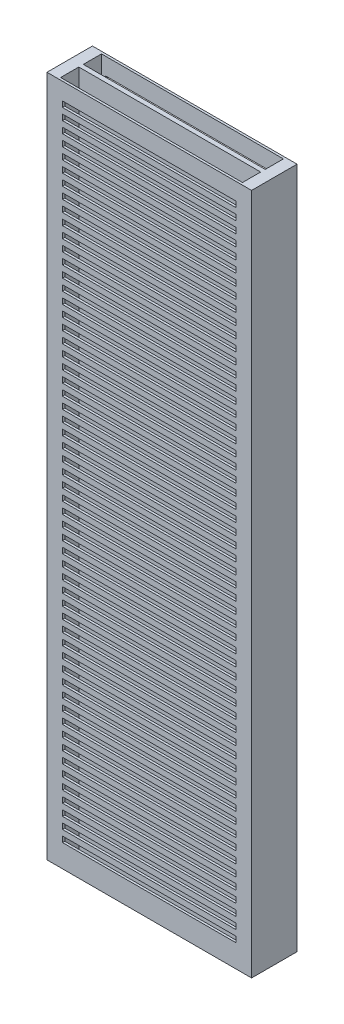
from build123d import *

# Parameters (mm, degrees)
SKETCH1_W                = 9
SKETCH1_H                = 2
BOSS_EXTRUDE1_DEPTH      = 15
CUT_EXTRUDE1_START       = -31
SKETCH2_W                = 8
SKETCH2_H                = 0.8
CUT_EXTRUDE1_DEPTH       = 32
SKETCH3_W                = 7.634272068
SKETCH3_H                = 0.25
CUT_EXTRUDE2_DEPTH       = 0.1
LPATTERN1_COUNT          = 57
LPATTERN1_PITCH          = 0.5
MIRROR2_COPY_1_SKETCH_W  = 7.634272068
MIRROR2_COPY_1_SKETCH_H  = 0.25
MIRROR2_COPY_1_DEPTH     = 0.1
MIRROR2_COPY_2_SKETCH_W  = 7.634272068
MIRROR2_COPY_2_SKETCH_H  = 0.25
MIRROR2_COPY_2_DEPTH     = 0.1
MIRROR2_COPY_3_SKETCH_W  = 7.634272068
MIRROR2_COPY_3_SKETCH_H  = 0.25
MIRROR2_COPY_3_DEPTH     = 0.1
MIRROR2_COPY_4_SKETCH_W  = 7.634272068
MIRROR2_COPY_4_SKETCH_H  = 0.25
MIRROR2_COPY_4_DEPTH     = 0.1
MIRROR2_COPY_5_SKETCH_W  = 7.634272068
MIRROR2_COPY_5_SKETCH_H  = 0.25
MIRROR2_COPY_5_DEPTH     = 0.1
MIRROR2_COPY_6_SKETCH_W  = 7.634272068
MIRROR2_COPY_6_SKETCH_H  = 0.25
MIRROR2_COPY_6_DEPTH     = 0.1
MIRROR2_COPY_7_SKETCH_W  = 7.634272068
MIRROR2_COPY_7_SKETCH_H  = 0.25
MIRROR2_COPY_7_DEPTH     = 0.1
MIRROR2_COPY_8_SKETCH_W  = 7.634272068
MIRROR2_COPY_8_SKETCH_H  = 0.25
MIRROR2_COPY_8_DEPTH     = 0.1
MIRROR2_COPY_9_SKETCH_W  = 7.634272068
MIRROR2_COPY_9_SKETCH_H  = 0.25
MIRROR2_COPY_9_DEPTH     = 0.1
MIRROR2_COPY_10_SKETCH_W = 7.634272068
MIRROR2_COPY_10_SKETCH_H = 0.25
MIRROR2_COPY_10_DEPTH    = 0.1
MIRROR2_COPY_11_SKETCH_W = 7.634272068
MIRROR2_COPY_11_SKETCH_H = 0.25
MIRROR2_COPY_11_DEPTH    = 0.1
MIRROR2_COPY_12_SKETCH_W = 7.634272068
MIRROR2_COPY_12_SKETCH_H = 0.25
MIRROR2_COPY_12_DEPTH    = 0.1
MIRROR2_COPY_13_SKETCH_W = 7.634272068
MIRROR2_COPY_13_SKETCH_H = 0.25
MIRROR2_COPY_13_DEPTH    = 0.1
MIRROR2_COPY_14_SKETCH_W = 7.634272068
MIRROR2_COPY_14_SKETCH_H = 0.25
MIRROR2_COPY_14_DEPTH    = 0.1
MIRROR2_COPY_15_SKETCH_W = 7.634272068
MIRROR2_COPY_15_SKETCH_H = 0.25
MIRROR2_COPY_15_DEPTH    = 0.1
MIRROR2_COPY_16_SKETCH_W = 7.634272068
MIRROR2_COPY_16_SKETCH_H = 0.25
MIRROR2_COPY_16_DEPTH    = 0.1
MIRROR2_COPY_17_SKETCH_W = 7.634272068
MIRROR2_COPY_17_SKETCH_H = 0.25
MIRROR2_COPY_17_DEPTH    = 0.1
MIRROR2_COPY_18_SKETCH_W = 7.634272068
MIRROR2_COPY_18_SKETCH_H = 0.25
MIRROR2_COPY_18_DEPTH    = 0.1
MIRROR2_COPY_19_SKETCH_W = 7.634272068
MIRROR2_COPY_19_SKETCH_H = 0.25
MIRROR2_COPY_19_DEPTH    = 0.1
MIRROR2_COPY_20_SKETCH_W = 7.634272068
MIRROR2_COPY_20_SKETCH_H = 0.25
MIRROR2_COPY_20_DEPTH    = 0.1
MIRROR2_COPY_21_SKETCH_W = 7.634272068
MIRROR2_COPY_21_SKETCH_H = 0.25
MIRROR2_COPY_21_DEPTH    = 0.1
MIRROR2_COPY_22_SKETCH_W = 7.634272068
MIRROR2_COPY_22_SKETCH_H = 0.25
MIRROR2_COPY_22_DEPTH    = 0.1
MIRROR2_COPY_23_SKETCH_W = 7.634272068
MIRROR2_COPY_23_SKETCH_H = 0.25
MIRROR2_COPY_23_DEPTH    = 0.1
MIRROR2_COPY_24_SKETCH_W = 7.634272068
MIRROR2_COPY_24_SKETCH_H = 0.25
MIRROR2_COPY_24_DEPTH    = 0.1
MIRROR2_COPY_25_SKETCH_W = 7.634272068
MIRROR2_COPY_25_SKETCH_H = 0.25
MIRROR2_COPY_25_DEPTH    = 0.1
MIRROR2_COPY_26_SKETCH_W = 7.634272068
MIRROR2_COPY_26_SKETCH_H = 0.25
MIRROR2_COPY_26_DEPTH    = 0.1
MIRROR2_COPY_27_SKETCH_W = 7.634272068
MIRROR2_COPY_27_SKETCH_H = 0.25
MIRROR2_COPY_27_DEPTH    = 0.1
MIRROR2_COPY_28_SKETCH_W = 7.634272068
MIRROR2_COPY_28_SKETCH_H = 0.25
MIRROR2_COPY_28_DEPTH    = 0.1
MIRROR2_COPY_29_SKETCH_W = 7.634272068
MIRROR2_COPY_29_SKETCH_H = 0.25
MIRROR2_COPY_29_DEPTH    = 0.1
MIRROR2_COPY_30_SKETCH_W = 7.634272068
MIRROR2_COPY_30_SKETCH_H = 0.25
MIRROR2_COPY_30_DEPTH    = 0.1
MIRROR2_COPY_31_SKETCH_W = 7.634272068
MIRROR2_COPY_31_SKETCH_H = 0.25
MIRROR2_COPY_31_DEPTH    = 0.1
MIRROR2_COPY_32_SKETCH_W = 7.634272068
MIRROR2_COPY_32_SKETCH_H = 0.25
MIRROR2_COPY_32_DEPTH    = 0.1
MIRROR2_COPY_33_SKETCH_W = 7.634272068
MIRROR2_COPY_33_SKETCH_H = 0.25
MIRROR2_COPY_33_DEPTH    = 0.1
MIRROR2_COPY_34_SKETCH_W = 7.634272068
MIRROR2_COPY_34_SKETCH_H = 0.25
MIRROR2_COPY_34_DEPTH    = 0.1
MIRROR2_COPY_35_SKETCH_W = 7.634272068
MIRROR2_COPY_35_SKETCH_H = 0.25
MIRROR2_COPY_35_DEPTH    = 0.1
MIRROR2_COPY_36_SKETCH_W = 7.634272068
MIRROR2_COPY_36_SKETCH_H = 0.25
MIRROR2_COPY_36_DEPTH    = 0.1
MIRROR2_COPY_37_SKETCH_W = 7.634272068
MIRROR2_COPY_37_SKETCH_H = 0.25
MIRROR2_COPY_37_DEPTH    = 0.1
MIRROR2_COPY_38_SKETCH_W = 7.634272068
MIRROR2_COPY_38_SKETCH_H = 0.25
MIRROR2_COPY_38_DEPTH    = 0.1
MIRROR2_COPY_39_SKETCH_W = 7.634272068
MIRROR2_COPY_39_SKETCH_H = 0.25
MIRROR2_COPY_39_DEPTH    = 0.1
MIRROR2_COPY_40_SKETCH_W = 7.634272068
MIRROR2_COPY_40_SKETCH_H = 0.25
MIRROR2_COPY_40_DEPTH    = 0.1
MIRROR2_COPY_41_SKETCH_W = 7.634272068
MIRROR2_COPY_41_SKETCH_H = 0.25
MIRROR2_COPY_41_DEPTH    = 0.1
MIRROR2_COPY_42_SKETCH_W = 7.634272068
MIRROR2_COPY_42_SKETCH_H = 0.25
MIRROR2_COPY_42_DEPTH    = 0.1
MIRROR2_COPY_43_SKETCH_W = 7.634272068
MIRROR2_COPY_43_SKETCH_H = 0.25
MIRROR2_COPY_43_DEPTH    = 0.1
MIRROR2_COPY_44_SKETCH_W = 7.634272068
MIRROR2_COPY_44_SKETCH_H = 0.25
MIRROR2_COPY_44_DEPTH    = 0.1
MIRROR2_COPY_45_SKETCH_W = 7.634272068
MIRROR2_COPY_45_SKETCH_H = 0.25
MIRROR2_COPY_45_DEPTH    = 0.1
MIRROR2_COPY_46_SKETCH_W = 7.634272068
MIRROR2_COPY_46_SKETCH_H = 0.25
MIRROR2_COPY_46_DEPTH    = 0.1
MIRROR2_COPY_47_SKETCH_W = 7.634272068
MIRROR2_COPY_47_SKETCH_H = 0.25
MIRROR2_COPY_47_DEPTH    = 0.1
MIRROR2_COPY_48_SKETCH_W = 7.634272068
MIRROR2_COPY_48_SKETCH_H = 0.25
MIRROR2_COPY_48_DEPTH    = 0.1
MIRROR2_COPY_49_SKETCH_W = 7.634272068
MIRROR2_COPY_49_SKETCH_H = 0.25
MIRROR2_COPY_49_DEPTH    = 0.1
MIRROR2_COPY_50_SKETCH_W = 7.634272068
MIRROR2_COPY_50_SKETCH_H = 0.25
MIRROR2_COPY_50_DEPTH    = 0.1
MIRROR2_COPY_51_SKETCH_W = 7.634272068
MIRROR2_COPY_51_SKETCH_H = 0.25
MIRROR2_COPY_51_DEPTH    = 0.1
MIRROR2_COPY_52_SKETCH_W = 7.634272068
MIRROR2_COPY_52_SKETCH_H = 0.25
MIRROR2_COPY_52_DEPTH    = 0.1
MIRROR2_COPY_53_SKETCH_W = 7.634272068
MIRROR2_COPY_53_SKETCH_H = 0.25
MIRROR2_COPY_53_DEPTH    = 0.1
MIRROR2_COPY_54_SKETCH_W = 7.634272068
MIRROR2_COPY_54_SKETCH_H = 0.25
MIRROR2_COPY_54_DEPTH    = 0.1
MIRROR2_COPY_55_SKETCH_W = 7.634272068
MIRROR2_COPY_55_SKETCH_H = 0.25
MIRROR2_COPY_55_DEPTH    = 0.1
MIRROR2_COPY_56_SKETCH_W = 7.634272068
MIRROR2_COPY_56_SKETCH_H = 0.25
MIRROR2_COPY_56_DEPTH    = 0.1


with BuildPart() as part:
    # Sketch1 → Boss-Extrude1 (new body, symmetric)
    with BuildSketch(Plane(origin=(0, 0, 0), x_dir=(1, 0, 0), z_dir=(0, 1, 0))):
        Rectangle(SKETCH1_W, SKETCH1_H)
    extrude(amount=BOSS_EXTRUDE1_DEPTH, both=True)

    # Sketch2 → Cut-Extrude1 (cut)
    with BuildSketch(Plane(origin=(0, 15, 0), x_dir=(1, 0, 0), z_dir=(0, 1, 0)).offset(CUT_EXTRUDE1_START)):
        with Locations((0, 0.5)):
            Rectangle(SKETCH2_W, SKETCH2_H)
    cut_extrude1 = extrude(amount=CUT_EXTRUDE1_DEPTH, mode=Mode.SUBTRACT)

    # Mirror1: Cut-Extrude1 across plane
    add(cut_extrude1.mirror(Plane.XY), mode=Mode.SUBTRACT)

    # Sketch3 → Cut-Extrude2 (cut)
    with BuildSketch(Plane.XY.offset(1)):
        with Locations((0, 14.125)):
            Rectangle(SKETCH3_W, SKETCH3_H)
    cut_extrude2 = extrude(amount=-CUT_EXTRUDE2_DEPTH, mode=Mode.SUBTRACT)

    # LPattern1: Cut-Extrude2 ×57
    with Locations(*[(0, -i * LPATTERN1_PITCH, 0) for i in range(1, LPATTERN1_COUNT)]):
        add(cut_extrude2, mode=Mode.SUBTRACT)

    # Mirror2: Cut-Extrude2 across plane
    add(cut_extrude2.mirror(Plane.XY), mode=Mode.SUBTRACT)

    # Mirror2 copy 1 sketch → Mirror2 copy 1 (cut)
    with BuildSketch(Plane(origin=(0, -0.5, -1), x_dir=(1, 0, 0), z_dir=(0, 0, -1))):
        with Locations((0, -14.125)):
            Rectangle(MIRROR2_COPY_1_SKETCH_W, MIRROR2_COPY_1_SKETCH_H)
    extrude(amount=-MIRROR2_COPY_1_DEPTH, mode=Mode.SUBTRACT)

    # Mirror2 copy 2 sketch → Mirror2 copy 2 (cut)
    with BuildSketch(Plane(origin=(0, -1, -1), x_dir=(1, 0, 0), z_dir=(0, 0, -1))):
        with Locations((0, -14.125)):
            Rectangle(MIRROR2_COPY_2_SKETCH_W, MIRROR2_COPY_2_SKETCH_H)
    extrude(amount=-MIRROR2_COPY_2_DEPTH, mode=Mode.SUBTRACT)

    # Mirror2 copy 3 sketch → Mirror2 copy 3 (cut)
    with BuildSketch(Plane(origin=(0, -1.5, -1), x_dir=(1, 0, 0), z_dir=(0, 0, -1))):
        with Locations((0, -14.125)):
            Rectangle(MIRROR2_COPY_3_SKETCH_W, MIRROR2_COPY_3_SKETCH_H)
    extrude(amount=-MIRROR2_COPY_3_DEPTH, mode=Mode.SUBTRACT)

    # Mirror2 copy 4 sketch → Mirror2 copy 4 (cut)
    with BuildSketch(Plane(origin=(0, -2, -1), x_dir=(1, 0, 0), z_dir=(0, 0, -1))):
        with Locations((0, -14.125)):
            Rectangle(MIRROR2_COPY_4_SKETCH_W, MIRROR2_COPY_4_SKETCH_H)
    extrude(amount=-MIRROR2_COPY_4_DEPTH, mode=Mode.SUBTRACT)

    # Mirror2 copy 5 sketch → Mirror2 copy 5 (cut)
    with BuildSketch(Plane(origin=(0, -2.5, -1), x_dir=(1, 0, 0), z_dir=(0, 0, -1))):
        with Locations((0, -14.125)):
            Rectangle(MIRROR2_COPY_5_SKETCH_W, MIRROR2_COPY_5_SKETCH_H)
    extrude(amount=-MIRROR2_COPY_5_DEPTH, mode=Mode.SUBTRACT)

    # Mirror2 copy 6 sketch → Mirror2 copy 6 (cut)
    with BuildSketch(Plane(origin=(0, -3, -1), x_dir=(1, 0, 0), z_dir=(0, 0, -1))):
        with Locations((0, -14.125)):
            Rectangle(MIRROR2_COPY_6_SKETCH_W, MIRROR2_COPY_6_SKETCH_H)
    extrude(amount=-MIRROR2_COPY_6_DEPTH, mode=Mode.SUBTRACT)

    # Mirror2 copy 7 sketch → Mirror2 copy 7 (cut)
    with BuildSketch(Plane(origin=(0, -3.5, -1), x_dir=(1, 0, 0), z_dir=(0, 0, -1))):
        with Locations((0, -14.125)):
            Rectangle(MIRROR2_COPY_7_SKETCH_W, MIRROR2_COPY_7_SKETCH_H)
    extrude(amount=-MIRROR2_COPY_7_DEPTH, mode=Mode.SUBTRACT)

    # Mirror2 copy 8 sketch → Mirror2 copy 8 (cut)
    with BuildSketch(Plane(origin=(0, -4, -1), x_dir=(1, 0, 0), z_dir=(0, 0, -1))):
        with Locations((0, -14.125)):
            Rectangle(MIRROR2_COPY_8_SKETCH_W, MIRROR2_COPY_8_SKETCH_H)
    extrude(amount=-MIRROR2_COPY_8_DEPTH, mode=Mode.SUBTRACT)

    # Mirror2 copy 9 sketch → Mirror2 copy 9 (cut)
    with BuildSketch(Plane(origin=(0, -4.5, -1), x_dir=(1, 0, 0), z_dir=(0, 0, -1))):
        with Locations((0, -14.125)):
            Rectangle(MIRROR2_COPY_9_SKETCH_W, MIRROR2_COPY_9_SKETCH_H)
    extrude(amount=-MIRROR2_COPY_9_DEPTH, mode=Mode.SUBTRACT)

    # Mirror2 copy 10 sketch → Mirror2 copy 10 (cut)
    with BuildSketch(Plane(origin=(0, -5, -1), x_dir=(1, 0, 0), z_dir=(0, 0, -1))):
        with Locations((0, -14.125)):
            Rectangle(MIRROR2_COPY_10_SKETCH_W, MIRROR2_COPY_10_SKETCH_H)
    extrude(amount=-MIRROR2_COPY_10_DEPTH, mode=Mode.SUBTRACT)

    # Mirror2 copy 11 sketch → Mirror2 copy 11 (cut)
    with BuildSketch(Plane(origin=(0, -5.5, -1), x_dir=(1, 0, 0), z_dir=(0, 0, -1))):
        with Locations((0, -14.125)):
            Rectangle(MIRROR2_COPY_11_SKETCH_W, MIRROR2_COPY_11_SKETCH_H)
    extrude(amount=-MIRROR2_COPY_11_DEPTH, mode=Mode.SUBTRACT)

    # Mirror2 copy 12 sketch → Mirror2 copy 12 (cut)
    with BuildSketch(Plane(origin=(0, -6, -1), x_dir=(1, 0, 0), z_dir=(0, 0, -1))):
        with Locations((0, -14.125)):
            Rectangle(MIRROR2_COPY_12_SKETCH_W, MIRROR2_COPY_12_SKETCH_H)
    extrude(amount=-MIRROR2_COPY_12_DEPTH, mode=Mode.SUBTRACT)

    # Mirror2 copy 13 sketch → Mirror2 copy 13 (cut)
    with BuildSketch(Plane(origin=(0, -6.5, -1), x_dir=(1, 0, 0), z_dir=(0, 0, -1))):
        with Locations((0, -14.125)):
            Rectangle(MIRROR2_COPY_13_SKETCH_W, MIRROR2_COPY_13_SKETCH_H)
    extrude(amount=-MIRROR2_COPY_13_DEPTH, mode=Mode.SUBTRACT)

    # Mirror2 copy 14 sketch → Mirror2 copy 14 (cut)
    with BuildSketch(Plane(origin=(0, -7, -1), x_dir=(1, 0, 0), z_dir=(0, 0, -1))):
        with Locations((0, -14.125)):
            Rectangle(MIRROR2_COPY_14_SKETCH_W, MIRROR2_COPY_14_SKETCH_H)
    extrude(amount=-MIRROR2_COPY_14_DEPTH, mode=Mode.SUBTRACT)

    # Mirror2 copy 15 sketch → Mirror2 copy 15 (cut)
    with BuildSketch(Plane(origin=(0, -7.5, -1), x_dir=(1, 0, 0), z_dir=(0, 0, -1))):
        with Locations((0, -14.125)):
            Rectangle(MIRROR2_COPY_15_SKETCH_W, MIRROR2_COPY_15_SKETCH_H)
    extrude(amount=-MIRROR2_COPY_15_DEPTH, mode=Mode.SUBTRACT)

    # Mirror2 copy 16 sketch → Mirror2 copy 16 (cut)
    with BuildSketch(Plane(origin=(0, -8, -1), x_dir=(1, 0, 0), z_dir=(0, 0, -1))):
        with Locations((0, -14.125)):
            Rectangle(MIRROR2_COPY_16_SKETCH_W, MIRROR2_COPY_16_SKETCH_H)
    extrude(amount=-MIRROR2_COPY_16_DEPTH, mode=Mode.SUBTRACT)

    # Mirror2 copy 17 sketch → Mirror2 copy 17 (cut)
    with BuildSketch(Plane(origin=(0, -8.5, -1), x_dir=(1, 0, 0), z_dir=(0, 0, -1))):
        with Locations((0, -14.125)):
            Rectangle(MIRROR2_COPY_17_SKETCH_W, MIRROR2_COPY_17_SKETCH_H)
    extrude(amount=-MIRROR2_COPY_17_DEPTH, mode=Mode.SUBTRACT)

    # Mirror2 copy 18 sketch → Mirror2 copy 18 (cut)
    with BuildSketch(Plane(origin=(0, -9, -1), x_dir=(1, 0, 0), z_dir=(0, 0, -1))):
        with Locations((0, -14.125)):
            Rectangle(MIRROR2_COPY_18_SKETCH_W, MIRROR2_COPY_18_SKETCH_H)
    extrude(amount=-MIRROR2_COPY_18_DEPTH, mode=Mode.SUBTRACT)

    # Mirror2 copy 19 sketch → Mirror2 copy 19 (cut)
    with BuildSketch(Plane(origin=(0, -9.5, -1), x_dir=(1, 0, 0), z_dir=(0, 0, -1))):
        with Locations((0, -14.125)):
            Rectangle(MIRROR2_COPY_19_SKETCH_W, MIRROR2_COPY_19_SKETCH_H)
    extrude(amount=-MIRROR2_COPY_19_DEPTH, mode=Mode.SUBTRACT)

    # Mirror2 copy 20 sketch → Mirror2 copy 20 (cut)
    with BuildSketch(Plane(origin=(0, -10, -1), x_dir=(1, 0, 0), z_dir=(0, 0, -1))):
        with Locations((0, -14.125)):
            Rectangle(MIRROR2_COPY_20_SKETCH_W, MIRROR2_COPY_20_SKETCH_H)
    extrude(amount=-MIRROR2_COPY_20_DEPTH, mode=Mode.SUBTRACT)

    # Mirror2 copy 21 sketch → Mirror2 copy 21 (cut)
    with BuildSketch(Plane(origin=(0, -10.5, -1), x_dir=(1, 0, 0), z_dir=(0, 0, -1))):
        with Locations((0, -14.125)):
            Rectangle(MIRROR2_COPY_21_SKETCH_W, MIRROR2_COPY_21_SKETCH_H)
    extrude(amount=-MIRROR2_COPY_21_DEPTH, mode=Mode.SUBTRACT)

    # Mirror2 copy 22 sketch → Mirror2 copy 22 (cut)
    with BuildSketch(Plane(origin=(0, -11, -1), x_dir=(1, 0, 0), z_dir=(0, 0, -1))):
        with Locations((0, -14.125)):
            Rectangle(MIRROR2_COPY_22_SKETCH_W, MIRROR2_COPY_22_SKETCH_H)
    extrude(amount=-MIRROR2_COPY_22_DEPTH, mode=Mode.SUBTRACT)

    # Mirror2 copy 23 sketch → Mirror2 copy 23 (cut)
    with BuildSketch(Plane(origin=(0, -11.5, -1), x_dir=(1, 0, 0), z_dir=(0, 0, -1))):
        with Locations((0, -14.125)):
            Rectangle(MIRROR2_COPY_23_SKETCH_W, MIRROR2_COPY_23_SKETCH_H)
    extrude(amount=-MIRROR2_COPY_23_DEPTH, mode=Mode.SUBTRACT)

    # Mirror2 copy 24 sketch → Mirror2 copy 24 (cut)
    with BuildSketch(Plane(origin=(0, -12, -1), x_dir=(1, 0, 0), z_dir=(0, 0, -1))):
        with Locations((0, -14.125)):
            Rectangle(MIRROR2_COPY_24_SKETCH_W, MIRROR2_COPY_24_SKETCH_H)
    extrude(amount=-MIRROR2_COPY_24_DEPTH, mode=Mode.SUBTRACT)

    # Mirror2 copy 25 sketch → Mirror2 copy 25 (cut)
    with BuildSketch(Plane(origin=(0, -12.5, -1), x_dir=(1, 0, 0), z_dir=(0, 0, -1))):
        with Locations((0, -14.125)):
            Rectangle(MIRROR2_COPY_25_SKETCH_W, MIRROR2_COPY_25_SKETCH_H)
    extrude(amount=-MIRROR2_COPY_25_DEPTH, mode=Mode.SUBTRACT)

    # Mirror2 copy 26 sketch → Mirror2 copy 26 (cut)
    with BuildSketch(Plane(origin=(0, -13, -1), x_dir=(1, 0, 0), z_dir=(0, 0, -1))):
        with Locations((0, -14.125)):
            Rectangle(MIRROR2_COPY_26_SKETCH_W, MIRROR2_COPY_26_SKETCH_H)
    extrude(amount=-MIRROR2_COPY_26_DEPTH, mode=Mode.SUBTRACT)

    # Mirror2 copy 27 sketch → Mirror2 copy 27 (cut)
    with BuildSketch(Plane(origin=(0, -13.5, -1), x_dir=(1, 0, 0), z_dir=(0, 0, -1))):
        with Locations((0, -14.125)):
            Rectangle(MIRROR2_COPY_27_SKETCH_W, MIRROR2_COPY_27_SKETCH_H)
    extrude(amount=-MIRROR2_COPY_27_DEPTH, mode=Mode.SUBTRACT)

    # Mirror2 copy 28 sketch → Mirror2 copy 28 (cut)
    with BuildSketch(Plane(origin=(0, -14, -1), x_dir=(1, 0, 0), z_dir=(0, 0, -1))):
        with Locations((0, -14.125)):
            Rectangle(MIRROR2_COPY_28_SKETCH_W, MIRROR2_COPY_28_SKETCH_H)
    extrude(amount=-MIRROR2_COPY_28_DEPTH, mode=Mode.SUBTRACT)

    # Mirror2 copy 29 sketch → Mirror2 copy 29 (cut)
    with BuildSketch(Plane(origin=(0, -14.5, -1), x_dir=(1, 0, 0), z_dir=(0, 0, -1))):
        with Locations((0, -14.125)):
            Rectangle(MIRROR2_COPY_29_SKETCH_W, MIRROR2_COPY_29_SKETCH_H)
    extrude(amount=-MIRROR2_COPY_29_DEPTH, mode=Mode.SUBTRACT)

    # Mirror2 copy 30 sketch → Mirror2 copy 30 (cut)
    with BuildSketch(Plane(origin=(0, -15, -1), x_dir=(1, 0, 0), z_dir=(0, 0, -1))):
        with Locations((0, -14.125)):
            Rectangle(MIRROR2_COPY_30_SKETCH_W, MIRROR2_COPY_30_SKETCH_H)
    extrude(amount=-MIRROR2_COPY_30_DEPTH, mode=Mode.SUBTRACT)

    # Mirror2 copy 31 sketch → Mirror2 copy 31 (cut)
    with BuildSketch(Plane(origin=(0, -15.5, -1), x_dir=(1, 0, 0), z_dir=(0, 0, -1))):
        with Locations((0, -14.125)):
            Rectangle(MIRROR2_COPY_31_SKETCH_W, MIRROR2_COPY_31_SKETCH_H)
    extrude(amount=-MIRROR2_COPY_31_DEPTH, mode=Mode.SUBTRACT)

    # Mirror2 copy 32 sketch → Mirror2 copy 32 (cut)
    with BuildSketch(Plane(origin=(0, -16, -1), x_dir=(1, 0, 0), z_dir=(0, 0, -1))):
        with Locations((0, -14.125)):
            Rectangle(MIRROR2_COPY_32_SKETCH_W, MIRROR2_COPY_32_SKETCH_H)
    extrude(amount=-MIRROR2_COPY_32_DEPTH, mode=Mode.SUBTRACT)

    # Mirror2 copy 33 sketch → Mirror2 copy 33 (cut)
    with BuildSketch(Plane(origin=(0, -16.5, -1), x_dir=(1, 0, 0), z_dir=(0, 0, -1))):
        with Locations((0, -14.125)):
            Rectangle(MIRROR2_COPY_33_SKETCH_W, MIRROR2_COPY_33_SKETCH_H)
    extrude(amount=-MIRROR2_COPY_33_DEPTH, mode=Mode.SUBTRACT)

    # Mirror2 copy 34 sketch → Mirror2 copy 34 (cut)
    with BuildSketch(Plane(origin=(0, -17, -1), x_dir=(1, 0, 0), z_dir=(0, 0, -1))):
        with Locations((0, -14.125)):
            Rectangle(MIRROR2_COPY_34_SKETCH_W, MIRROR2_COPY_34_SKETCH_H)
    extrude(amount=-MIRROR2_COPY_34_DEPTH, mode=Mode.SUBTRACT)

    # Mirror2 copy 35 sketch → Mirror2 copy 35 (cut)
    with BuildSketch(Plane(origin=(0, -17.5, -1), x_dir=(1, 0, 0), z_dir=(0, 0, -1))):
        with Locations((0, -14.125)):
            Rectangle(MIRROR2_COPY_35_SKETCH_W, MIRROR2_COPY_35_SKETCH_H)
    extrude(amount=-MIRROR2_COPY_35_DEPTH, mode=Mode.SUBTRACT)

    # Mirror2 copy 36 sketch → Mirror2 copy 36 (cut)
    with BuildSketch(Plane(origin=(0, -18, -1), x_dir=(1, 0, 0), z_dir=(0, 0, -1))):
        with Locations((0, -14.125)):
            Rectangle(MIRROR2_COPY_36_SKETCH_W, MIRROR2_COPY_36_SKETCH_H)
    extrude(amount=-MIRROR2_COPY_36_DEPTH, mode=Mode.SUBTRACT)

    # Mirror2 copy 37 sketch → Mirror2 copy 37 (cut)
    with BuildSketch(Plane(origin=(0, -18.5, -1), x_dir=(1, 0, 0), z_dir=(0, 0, -1))):
        with Locations((0, -14.125)):
            Rectangle(MIRROR2_COPY_37_SKETCH_W, MIRROR2_COPY_37_SKETCH_H)
    extrude(amount=-MIRROR2_COPY_37_DEPTH, mode=Mode.SUBTRACT)

    # Mirror2 copy 38 sketch → Mirror2 copy 38 (cut)
    with BuildSketch(Plane(origin=(0, -19, -1), x_dir=(1, 0, 0), z_dir=(0, 0, -1))):
        with Locations((0, -14.125)):
            Rectangle(MIRROR2_COPY_38_SKETCH_W, MIRROR2_COPY_38_SKETCH_H)
    extrude(amount=-MIRROR2_COPY_38_DEPTH, mode=Mode.SUBTRACT)

    # Mirror2 copy 39 sketch → Mirror2 copy 39 (cut)
    with BuildSketch(Plane(origin=(0, -19.5, -1), x_dir=(1, 0, 0), z_dir=(0, 0, -1))):
        with Locations((0, -14.125)):
            Rectangle(MIRROR2_COPY_39_SKETCH_W, MIRROR2_COPY_39_SKETCH_H)
    extrude(amount=-MIRROR2_COPY_39_DEPTH, mode=Mode.SUBTRACT)

    # Mirror2 copy 40 sketch → Mirror2 copy 40 (cut)
    with BuildSketch(Plane(origin=(0, -20, -1), x_dir=(1, 0, 0), z_dir=(0, 0, -1))):
        with Locations((0, -14.125)):
            Rectangle(MIRROR2_COPY_40_SKETCH_W, MIRROR2_COPY_40_SKETCH_H)
    extrude(amount=-MIRROR2_COPY_40_DEPTH, mode=Mode.SUBTRACT)

    # Mirror2 copy 41 sketch → Mirror2 copy 41 (cut)
    with BuildSketch(Plane(origin=(0, -20.5, -1), x_dir=(1, 0, 0), z_dir=(0, 0, -1))):
        with Locations((0, -14.125)):
            Rectangle(MIRROR2_COPY_41_SKETCH_W, MIRROR2_COPY_41_SKETCH_H)
    extrude(amount=-MIRROR2_COPY_41_DEPTH, mode=Mode.SUBTRACT)

    # Mirror2 copy 42 sketch → Mirror2 copy 42 (cut)
    with BuildSketch(Plane(origin=(0, -21, -1), x_dir=(1, 0, 0), z_dir=(0, 0, -1))):
        with Locations((0, -14.125)):
            Rectangle(MIRROR2_COPY_42_SKETCH_W, MIRROR2_COPY_42_SKETCH_H)
    extrude(amount=-MIRROR2_COPY_42_DEPTH, mode=Mode.SUBTRACT)

    # Mirror2 copy 43 sketch → Mirror2 copy 43 (cut)
    with BuildSketch(Plane(origin=(0, -21.5, -1), x_dir=(1, 0, 0), z_dir=(0, 0, -1))):
        with Locations((0, -14.125)):
            Rectangle(MIRROR2_COPY_43_SKETCH_W, MIRROR2_COPY_43_SKETCH_H)
    extrude(amount=-MIRROR2_COPY_43_DEPTH, mode=Mode.SUBTRACT)

    # Mirror2 copy 44 sketch → Mirror2 copy 44 (cut)
    with BuildSketch(Plane(origin=(0, -22, -1), x_dir=(1, 0, 0), z_dir=(0, 0, -1))):
        with Locations((0, -14.125)):
            Rectangle(MIRROR2_COPY_44_SKETCH_W, MIRROR2_COPY_44_SKETCH_H)
    extrude(amount=-MIRROR2_COPY_44_DEPTH, mode=Mode.SUBTRACT)

    # Mirror2 copy 45 sketch → Mirror2 copy 45 (cut)
    with BuildSketch(Plane(origin=(0, -22.5, -1), x_dir=(1, 0, 0), z_dir=(0, 0, -1))):
        with Locations((0, -14.125)):
            Rectangle(MIRROR2_COPY_45_SKETCH_W, MIRROR2_COPY_45_SKETCH_H)
    extrude(amount=-MIRROR2_COPY_45_DEPTH, mode=Mode.SUBTRACT)

    # Mirror2 copy 46 sketch → Mirror2 copy 46 (cut)
    with BuildSketch(Plane(origin=(0, -23, -1), x_dir=(1, 0, 0), z_dir=(0, 0, -1))):
        with Locations((0, -14.125)):
            Rectangle(MIRROR2_COPY_46_SKETCH_W, MIRROR2_COPY_46_SKETCH_H)
    extrude(amount=-MIRROR2_COPY_46_DEPTH, mode=Mode.SUBTRACT)

    # Mirror2 copy 47 sketch → Mirror2 copy 47 (cut)
    with BuildSketch(Plane(origin=(0, -23.5, -1), x_dir=(1, 0, 0), z_dir=(0, 0, -1))):
        with Locations((0, -14.125)):
            Rectangle(MIRROR2_COPY_47_SKETCH_W, MIRROR2_COPY_47_SKETCH_H)
    extrude(amount=-MIRROR2_COPY_47_DEPTH, mode=Mode.SUBTRACT)

    # Mirror2 copy 48 sketch → Mirror2 copy 48 (cut)
    with BuildSketch(Plane(origin=(0, -24, -1), x_dir=(1, 0, 0), z_dir=(0, 0, -1))):
        with Locations((0, -14.125)):
            Rectangle(MIRROR2_COPY_48_SKETCH_W, MIRROR2_COPY_48_SKETCH_H)
    extrude(amount=-MIRROR2_COPY_48_DEPTH, mode=Mode.SUBTRACT)

    # Mirror2 copy 49 sketch → Mirror2 copy 49 (cut)
    with BuildSketch(Plane(origin=(0, -24.5, -1), x_dir=(1, 0, 0), z_dir=(0, 0, -1))):
        with Locations((0, -14.125)):
            Rectangle(MIRROR2_COPY_49_SKETCH_W, MIRROR2_COPY_49_SKETCH_H)
    extrude(amount=-MIRROR2_COPY_49_DEPTH, mode=Mode.SUBTRACT)

    # Mirror2 copy 50 sketch → Mirror2 copy 50 (cut)
    with BuildSketch(Plane(origin=(0, -25, -1), x_dir=(1, 0, 0), z_dir=(0, 0, -1))):
        with Locations((0, -14.125)):
            Rectangle(MIRROR2_COPY_50_SKETCH_W, MIRROR2_COPY_50_SKETCH_H)
    extrude(amount=-MIRROR2_COPY_50_DEPTH, mode=Mode.SUBTRACT)

    # Mirror2 copy 51 sketch → Mirror2 copy 51 (cut)
    with BuildSketch(Plane(origin=(0, -25.5, -1), x_dir=(1, 0, 0), z_dir=(0, 0, -1))):
        with Locations((0, -14.125)):
            Rectangle(MIRROR2_COPY_51_SKETCH_W, MIRROR2_COPY_51_SKETCH_H)
    extrude(amount=-MIRROR2_COPY_51_DEPTH, mode=Mode.SUBTRACT)

    # Mirror2 copy 52 sketch → Mirror2 copy 52 (cut)
    with BuildSketch(Plane(origin=(0, -26, -1), x_dir=(1, 0, 0), z_dir=(0, 0, -1))):
        with Locations((0, -14.125)):
            Rectangle(MIRROR2_COPY_52_SKETCH_W, MIRROR2_COPY_52_SKETCH_H)
    extrude(amount=-MIRROR2_COPY_52_DEPTH, mode=Mode.SUBTRACT)

    # Mirror2 copy 53 sketch → Mirror2 copy 53 (cut)
    with BuildSketch(Plane(origin=(0, -26.5, -1), x_dir=(1, 0, 0), z_dir=(0, 0, -1))):
        with Locations((0, -14.125)):
            Rectangle(MIRROR2_COPY_53_SKETCH_W, MIRROR2_COPY_53_SKETCH_H)
    extrude(amount=-MIRROR2_COPY_53_DEPTH, mode=Mode.SUBTRACT)

    # Mirror2 copy 54 sketch → Mirror2 copy 54 (cut)
    with BuildSketch(Plane(origin=(0, -27, -1), x_dir=(1, 0, 0), z_dir=(0, 0, -1))):
        with Locations((0, -14.125)):
            Rectangle(MIRROR2_COPY_54_SKETCH_W, MIRROR2_COPY_54_SKETCH_H)
    extrude(amount=-MIRROR2_COPY_54_DEPTH, mode=Mode.SUBTRACT)

    # Mirror2 copy 55 sketch → Mirror2 copy 55 (cut)
    with BuildSketch(Plane(origin=(0, -27.5, -1), x_dir=(1, 0, 0), z_dir=(0, 0, -1))):
        with Locations((0, -14.125)):
            Rectangle(MIRROR2_COPY_55_SKETCH_W, MIRROR2_COPY_55_SKETCH_H)
    extrude(amount=-MIRROR2_COPY_55_DEPTH, mode=Mode.SUBTRACT)

    # Mirror2 copy 56 sketch → Mirror2 copy 56 (cut)
    with BuildSketch(Plane(origin=(0, -28, -1), x_dir=(1, 0, 0), z_dir=(0, 0, -1))):
        with Locations((0, -14.125)):
            Rectangle(MIRROR2_COPY_56_SKETCH_W, MIRROR2_COPY_56_SKETCH_H)
    extrude(amount=-MIRROR2_COPY_56_DEPTH, mode=Mode.SUBTRACT)


solid = part.part
